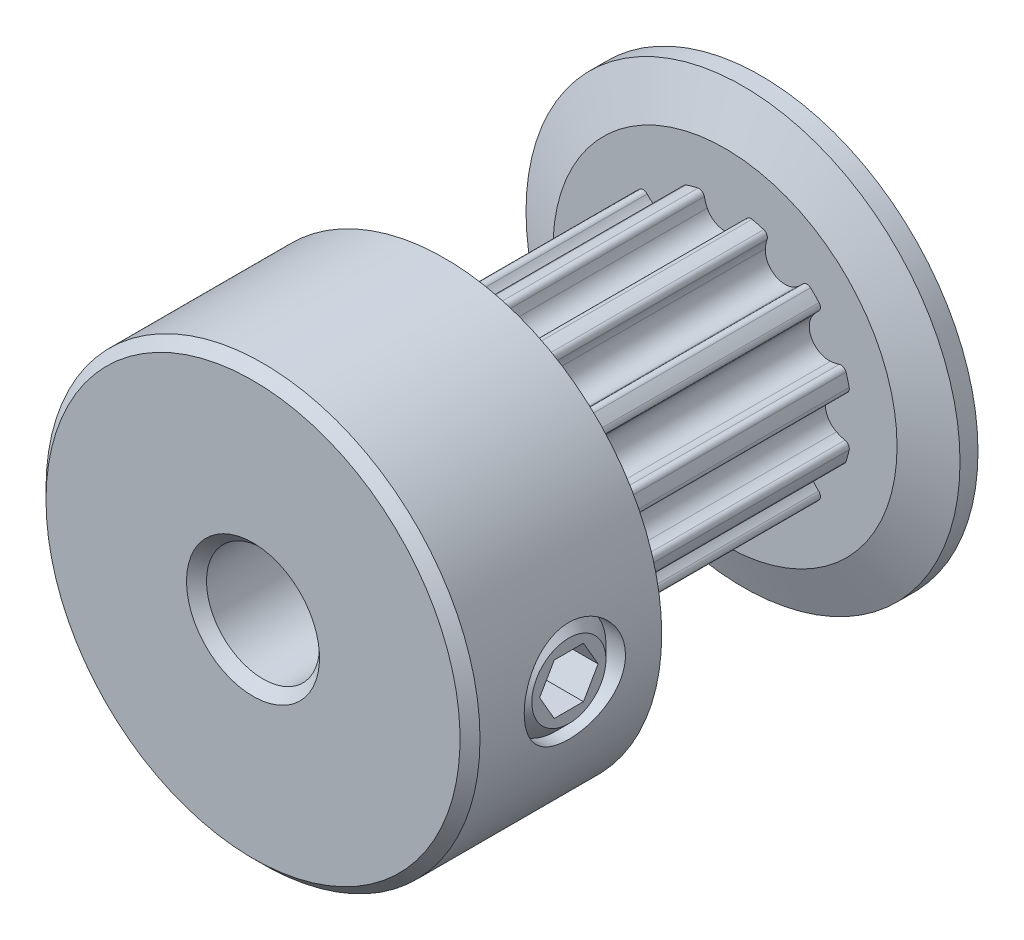
from build123d import *

# Parameters (mm, degrees)
CUT_EXTRUDE1_START = 1.245
CUT_EXTRUDE1_DEPTH = 7.37
CIRPATTERN1_COUNT  = 12
SKETCH4_R          = 1.4224
CUT_EXTRUDE2_DEPTH = 12.190650428
CUT_EXTRUDE3_DEPTH = 1.0668
CHAMFER1_SIZE      = 0.28075


with BuildPart() as part:
    # Sketch2 → Revolve1 (revolve)
    with BuildSketch(Plane(origin=(0, 0, 0), x_dir=(0, 0, -1), z_dir=(1, 0, 0)), mode=Mode.PRIVATE) as revolve1_sk:
        Polygon((-7.135, 1.5875), (7.135, 1.5875), (7.135, 6.096), (6.63, 6.096), (6.125, 4.83225), (6.125, 3.5685), (-1.245, 3.5685), (-1.245, 4.83225), (-1.75, 6.096), (-7.135, 6.096), align=None)
    revolve(revolve1_sk.sketch.rotate(Axis((0, 0, 7.135), (0, 0, -1)), 90), axis=Axis((0, 0, 7.135), (0, 0, -1)))

    # Sketch3 → Cut-Extrude1 (cut)
    with BuildSketch(Plane.XY.offset(CUT_EXTRUDE1_START)):
        with BuildLine():
            Line((3.566654882, 6.096), (-3.566654882, 6.096))
            Line((-3.566654882, 6.096), (-1.802078902, 3.080049331))
            ThreePointArc((-1.802078902, 3.080049331), (-1.296607682, 3.324605355), (-0.759031417, 3.486841487))
            ThreePointArc((-0.759031417, 3.486841487), (-0.645131247, 3.465879975), (-0.580109509, 3.370042573))
            ThreePointArc((-0.580109509, 3.370042573), (-0.547109503, 3.247589437), (-0.498876404, 3.130297753))
            ThreePointArc((-0.498876404, 3.130297753), (0, 2.8185), (0.498876404, 3.130297753))
            ThreePointArc((0.498876404, 3.130297753), (0.547109503, 3.247589437), (0.580109509, 3.370042573))
            ThreePointArc((0.580109509, 3.370042573), (0.645131247, 3.465879975), (0.759031417, 3.486841487))
            ThreePointArc((0.759031417, 3.486841487), (1.296607682, 3.324605355), (1.802078902, 3.080049331))
            Line((1.802078902, 3.080049331), (3.566654882, 6.096))
        make_face()
    cut_extrude1 = extrude(amount=-CUT_EXTRUDE1_DEPTH, mode=Mode.SUBTRACT)

    # CirPattern1: Cut-Extrude1 ×12 about axis
    cirpattern1_axis = Axis((0, 0, 0), (0, 0, 1))
    for i in range(1, CIRPATTERN1_COUNT):
        add(cut_extrude1.rotate(cirpattern1_axis, i * 360 / CIRPATTERN1_COUNT), mode=Mode.SUBTRACT)

    # Sketch4 → Cut-Extrude2 (cut, through all)
    with BuildSketch(Plane(origin=(0, 0, 0), x_dir=(0, -1, 0), z_dir=(1, 0, 0))):
        with Locations(Location((0, -4.19, 0), (0, 0, 270))):
            Circle(SKETCH4_R)
    extrude(amount=CUT_EXTRUDE2_DEPTH, mode=Mode.SUBTRACT)

    # Sketch5 → Revolve2 (revolve)
    with BuildSketch(Plane.XY.offset(4.19), mode=Mode.PRIVATE) as revolve2_sk:
        Polygon((1.5875, -1.0414), (1.5875, 0), (5.927730952, 0), (5.927730952, -1.0414), (5.546730952, -1.4224), (1.9685, -1.4224), align=None)
    revolve(revolve2_sk.sketch.rotate(Axis((1.5875, 0, 4.19), (1, 0, 0)), 270), axis=Axis((1.5875, 0, 4.19), (1, 0, 0)))

    # Sketch6 → Cut-Extrude3 (cut)
    with BuildSketch(Plane(origin=(5.927730952, 5.384140679, 0), x_dir=(0, -1, 0), z_dir=(-1, 0, 0))):
        Polygon((5.384140679, 5.011223023), (4.672940679, 4.600611511), (4.672940679, 3.779388489), (5.384140679, 3.368776977), (6.095340679, 3.779388489), (6.095340679, 4.600611511), align=None)
    extrude(amount=CUT_EXTRUDE3_DEPTH, mode=Mode.SUBTRACT)

    # Chamfer1
    chamfer1_edges = [part.edges().sort_by_distance(p)[0] for p in [
        (-1.5875, 0, 7.135),
        (-6.096, 0, 7.135),
    ]]
    chamfer(chamfer1_edges, length=CHAMFER1_SIZE)


solid = part.part
